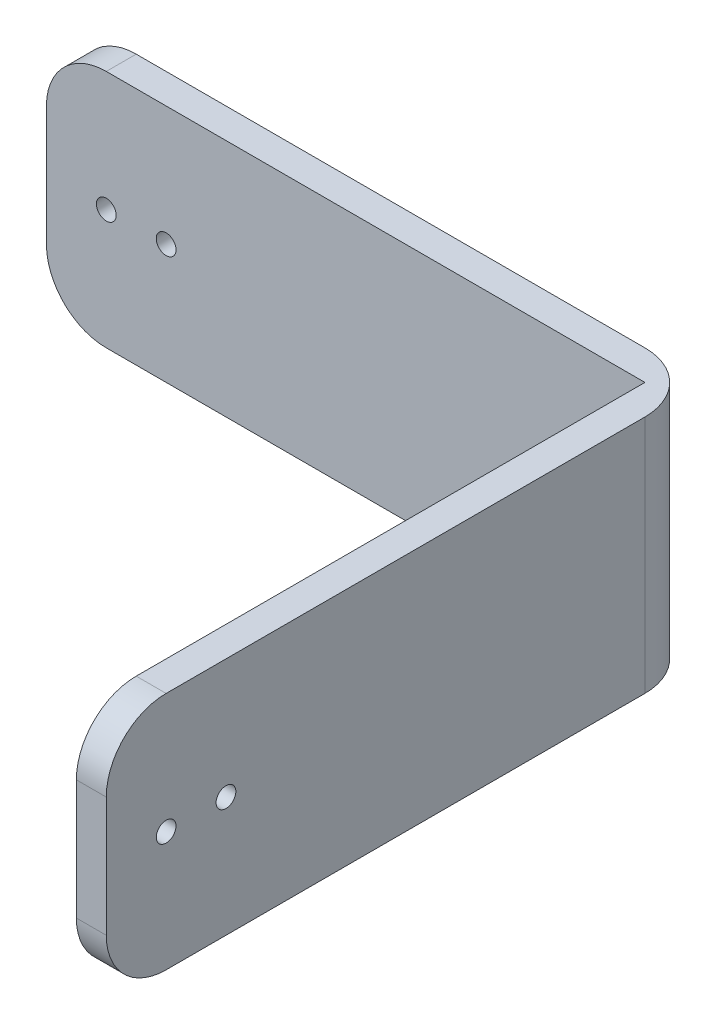
from build123d import *

# Parameters (mm, degrees)
EXTRUSION1_DEPTH   = 1
EXTRUSION3_DEPTH   = 1
D_GAGEMENT_00001_D = 0.6604
D_GAGEMENT_00002_D = 0.6604
D_GAGEMENT_00004_D = 0.6604
D_GAGEMENT_00005_D = 0.6604
CONG_2_R           = 2


with BuildPart() as part:
    # Esquisse1 → Extrusion1 (new body)
    with BuildSketch(Plane.XY):
        with BuildLine():
            Line((-52.829500905, 27.414750453), (-34.829500905, 27.414750453))
            Line((-34.829500905, 27.414750453), (-34.829500905, 19.414750453))
            Line((-34.829500905, 19.414750453), (-52.829500905, 19.414750453))
            ThreePointArc((-52.829500905, 19.414750453), (-54.243714467, 20.00053689), (-54.829500905, 21.414750453))
            Line((-54.829500905, 21.414750453), (-54.829500905, 25.414750453))
            ThreePointArc((-54.829500905, 25.414750453), (-54.243714467, 26.828964015), (-52.829500905, 27.414750453))
        make_face()
    extrude(amount=-EXTRUSION1_DEPTH)

    # Esquisse4 → Extrusion3 (add)
    with BuildSketch(Plane(origin=(-34.829500905, 0, 0), x_dir=(0, 0, -1), z_dir=(1, 0, 0))):
        with BuildLine():
            Line((1, 27.414750453), (-17, 27.414750453))
            ThreePointArc((-17, 27.414750453), (-18.414213562, 26.828964015), (-19, 25.414750453))
            Line((-19, 25.414750453), (-19, 21.414750453))
            ThreePointArc((-19, 21.414750453), (-18.414213562, 20.00053689), (-17, 19.414750453))
            Line((-17, 19.414750453), (1, 19.414750453))
            Line((1, 19.414750453), (1, 27.414750453))
        make_face()
    extrude(amount=EXTRUSION3_DEPTH)

    # Dégagement #00001 (through all)
    with Locations(Plane(origin=(-52.829500905, 23.414750453, 0), x_dir=(1, 0, 0), z_dir=(0, 0, 1))):
        with Locations((0, 0)):
            Hole(D_GAGEMENT_00001_D / 2)

    # Dégagement #00002 (through all)
    with Locations(Plane(origin=(-50.829500905, 23.414750453, 0), x_dir=(1, 0, 0), z_dir=(0, 0, 1))):
        with Locations((0, 0)):
            Hole(D_GAGEMENT_00002_D / 2)

    # Dégagement #00004 (through all)
    with Locations(Plane(origin=(-33.829500905, 23.414750453, 17), x_dir=(0, 0, 1), z_dir=(1, 0, 0))):
        with Locations((0, 0)):
            Hole(D_GAGEMENT_00004_D / 2)

    # Dégagement #00005 (through all)
    with Locations(Plane(origin=(-33.829500905, 23.414750453, 15), x_dir=(0, 0, 1), z_dir=(1, 0, 0))):
        with Locations((0, 0)):
            Hole(D_GAGEMENT_00005_D / 2)

    # Congé2
    cong_2_edges = [part.edges().sort_by_distance(p)[0] for p in [
        (-33.829500905, 23.414750453, -1),
    ]]
    fillet(cong_2_edges, radius=CONG_2_R)


solid = part.part
